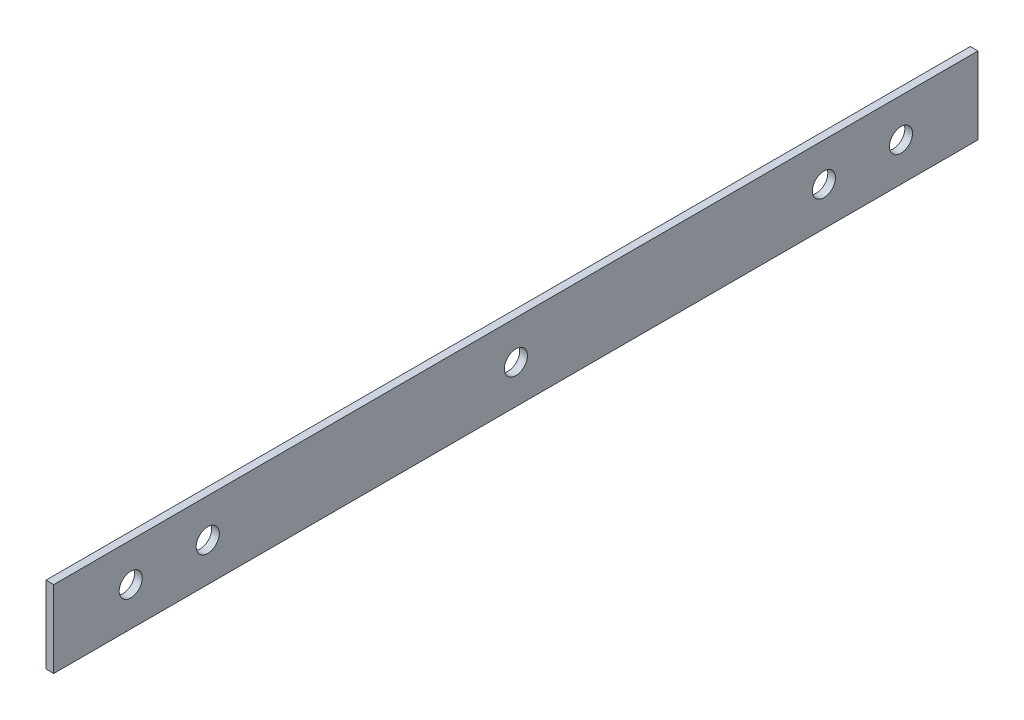
from build123d import *

# Parameters (mm, degrees)
SKETCH_1_W      = 120
SKETCH_1_H      = 10
SKETCH_1_R      = 1.5
EXTRUDE_1_DEPTH = 1


with BuildPart() as part:
    # 草图1 → 凸台-拉伸1 (new body)
    with BuildSketch(Plane(origin=(0, 0, 0), x_dir=(0, 0, -1), z_dir=(1, 0, 0))):
        with Locations((-42.952312312, -1.848982316)):
            Rectangle(SKETCH_1_W, SKETCH_1_H)
        with Locations((-82.952312312, -1.848982316)):
            Circle(SKETCH_1_R, mode=Mode.SUBTRACT)
        with Locations((-2.952312312, -1.848982316)):
            Circle(SKETCH_1_R, mode=Mode.SUBTRACT)
        with Locations((-92.952312312, -1.848982316)):
            Circle(SKETCH_1_R, mode=Mode.SUBTRACT)
        with Locations((7.047687688, -1.848982316)):
            Circle(SKETCH_1_R, mode=Mode.SUBTRACT)
        with Locations((-42.952312312, -1.848982316)):
            Circle(SKETCH_1_R, mode=Mode.SUBTRACT)
    extrude(amount=EXTRUDE_1_DEPTH)


solid = part.part
